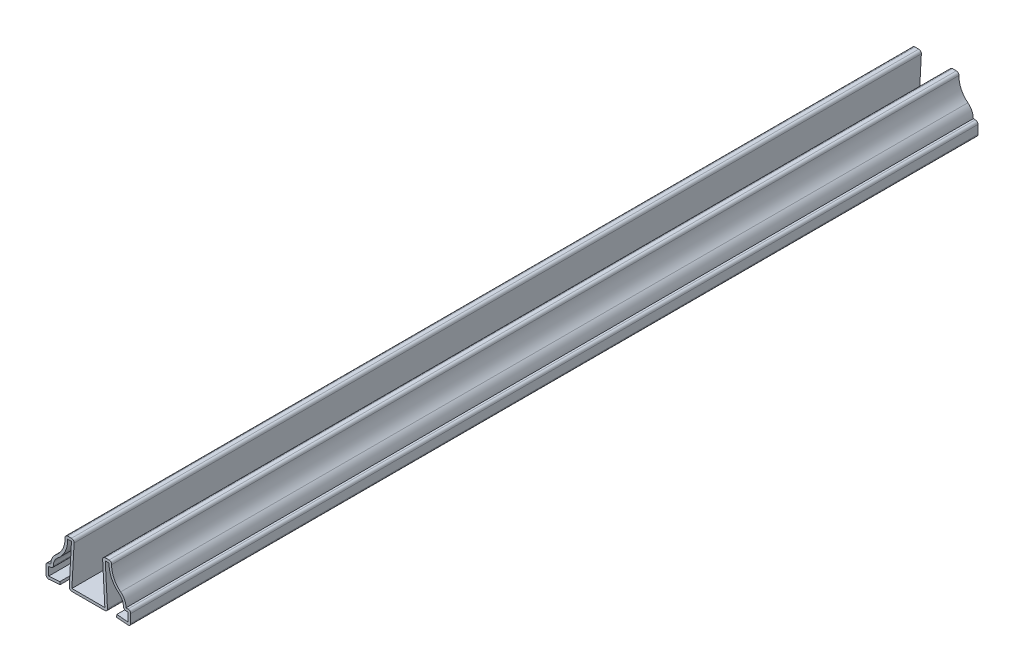
from build123d import *

# Parameters (mm, degrees)
EXTRUDE_THIN1_DEPTH = 285.75
FILLET1_R           = 0.889


with BuildPart() as part:
    # Sketch1 → Extrude-Thin1 (new body)
    with BuildSketch(Plane.XY):
        with BuildLine():
            Line((9.525, 0.396875), (14.2875, 0))
            Line((14.2875, 0), (14.2875, 4.7625))
            Line((14.2875, 4.7625), (12.7, 4.7625))
            ThreePointArc((12.7, 4.7625), (12.221883718, 6.842274605), (10.883532847, 8.504464286))
            ThreePointArc((10.883532847, 8.504464286), (8.423051877, 11.795038582), (7.9375, 15.875))
            Line((7.9375, 15.875), (4.7625, 15.875))
            Line((4.7625, 15.875), (5.55625, 1.285875))
            Line((5.55625, 1.285875), (-5.55625, 1.285875))
            Line((-5.55625, 1.285875), (-4.7625, 15.875))
            Line((-4.7625, 15.875), (-7.9375, 15.875))
            ThreePointArc((-7.9375, 15.875), (-8.423051877, 11.795038582), (-10.883532847, 8.504464286))
            ThreePointArc((-10.883532847, 8.504464286), (-12.221883718, 6.842274605), (-12.7, 4.7625))
            Line((-12.7, 4.7625), (-14.2875, 4.7625))
            Line((-14.2875, 4.7625), (-14.2875, 0))
            Line((-14.2875, 0), (-9.525, 0.396875))
            Line((-9.525, 0.396875), (-9.598827432, 1.282804179))
            Line((-9.598827432, 1.282804179), (-13.3985, 0.966164798))
            Line((-13.3985, 0.966164798), (-13.3985, 3.8735))
            Line((-13.3985, 3.8735), (-11.707603613, 3.8735))
            ThreePointArc((-11.707603613, 3.8735), (-11.594220702, 6.040152518), (-10.333606715, 7.805964286))
            ThreePointArc((-10.333606715, 7.805964286), (-7.800475833, 10.997107398), (-6.970486535, 14.986))
            Line((-6.970486535, 14.986), (-5.701182591, 14.986))
            Line((-5.701182591, 14.986), (-6.494932591, 0.396875))
            Line((-6.494932591, 0.396875), (6.494932591, 0.396875))
            Line((6.494932591, 0.396875), (5.701182591, 14.986))
            Line((5.701182591, 14.986), (6.970486535, 14.986))
            ThreePointArc((6.970486535, 14.986), (7.800475833, 10.997107398), (10.333606715, 7.805964286))
            ThreePointArc((10.333606715, 7.805964286), (11.594220702, 6.040152518), (11.707603613, 3.8735))
            Line((11.707603613, 3.8735), (13.3985, 3.8735))
            Line((13.3985, 3.8735), (13.3985, 0.966164798))
            Line((13.3985, 0.966164798), (9.598827432, 1.282804179))
            Line((9.598827432, 1.282804179), (9.525, 0.396875))
        make_face()
    extrude(amount=-EXTRUDE_THIN1_DEPTH)

    # Fillet1
    fillet1_edges = [part.edges().sort_by_distance(p)[0] for p in [
        (11.707603613, 3.8735, -142.875),
        (6.494932591, 0.396875, -142.875),
        (-6.494932591, 0.396875, -142.875),
        (-11.707603613, 3.8735, -142.875),
        (-14.2875, 0, -142.875),
        (-14.2875, 4.7625, -142.875),
        (-7.9375, 15.875, -142.875),
        (-4.7625, 15.875, -142.875),
        (4.7625, 15.875, -142.875),
        (7.9375, 15.875, -142.875),
        (14.2875, 4.7625, -142.875),
        (14.2875, 0, -142.875),
    ]]
    fillet(fillet1_edges, radius=FILLET1_R)


solid = part.part
